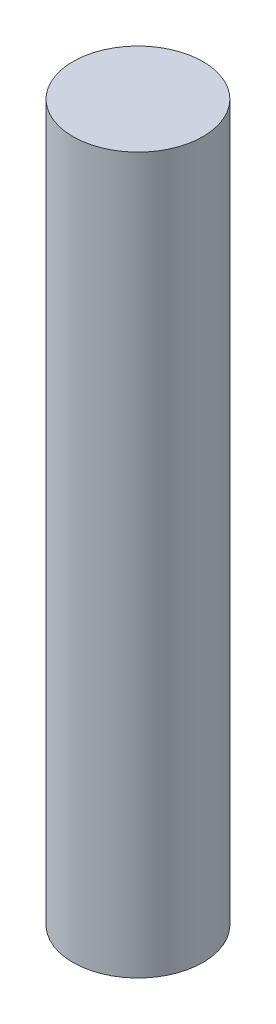
from build123d import *

# Parameters (mm, degrees)
SKETCH1_R           = 10
BOSS_EXTRUDE1_DEPTH = 110


with BuildPart() as part:
    # Sketch1 → Boss-Extrude1 (new body)
    with BuildSketch(Plane(origin=(0, 0, 0), x_dir=(1, 0, 0), z_dir=(0, 1, 0))):
        Circle(SKETCH1_R)
    extrude(amount=BOSS_EXTRUDE1_DEPTH)


solid = part.part
